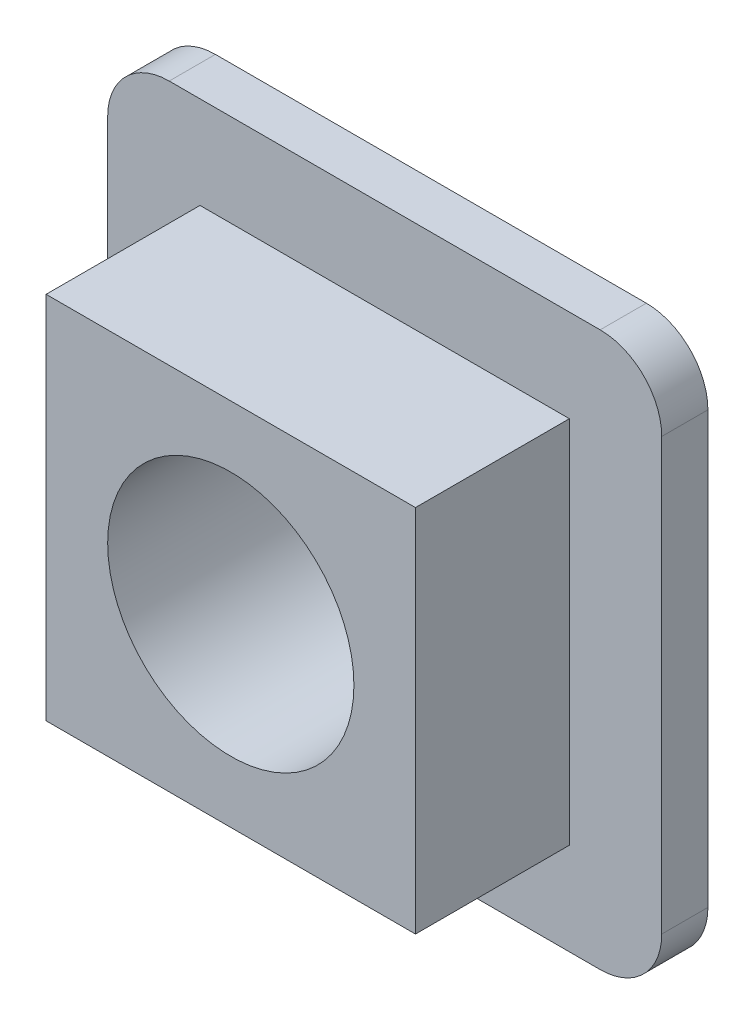
from build123d import *

# Parameters (mm, degrees)
BOSS_EXTRUDE1_DEPTH = 1.5
SKETCH2_W           = 12
SKETCH2_H           = 12
BOSS_EXTRUDE2_DEPTH = 5
SKETCH3_R           = 4
CUT_EXTRUDE1_DEPTH  = 7.5


with BuildPart() as part:
    # Sketch1 → Boss-Extrude1 (new body)
    with BuildSketch(Plane.XY):
        with BuildLine():
            Line((2, 0), (16, 0))
            ThreePointArc((16, 0), (17.414213562, 0.585786438), (18, 2))
            Line((18, 2), (18, 16))
            ThreePointArc((18, 16), (17.414213562, 17.414213562), (16, 18))
            Line((16, 18), (2, 18))
            ThreePointArc((2, 18), (0.585786438, 17.414213562), (0, 16))
            Line((0, 16), (0, 2))
            ThreePointArc((0, 2), (0.585786438, 0.585786438), (2, 0))
        make_face()
    extrude(amount=BOSS_EXTRUDE1_DEPTH)

    # Sketch2 → Boss-Extrude2 (add)
    with BuildSketch(Plane.XY.offset(1.5)):
        with Locations((9, 9)):
            Rectangle(SKETCH2_W, SKETCH2_H)
    extrude(amount=BOSS_EXTRUDE2_DEPTH)

    # Sketch3 → Cut-Extrude1 (cut, through all)
    with BuildSketch(Plane.XY.offset(6.5)):
        with Locations((9, 9)):
            Circle(SKETCH3_R)
    extrude(amount=-CUT_EXTRUDE1_DEPTH, mode=Mode.SUBTRACT)


solid = part.part
